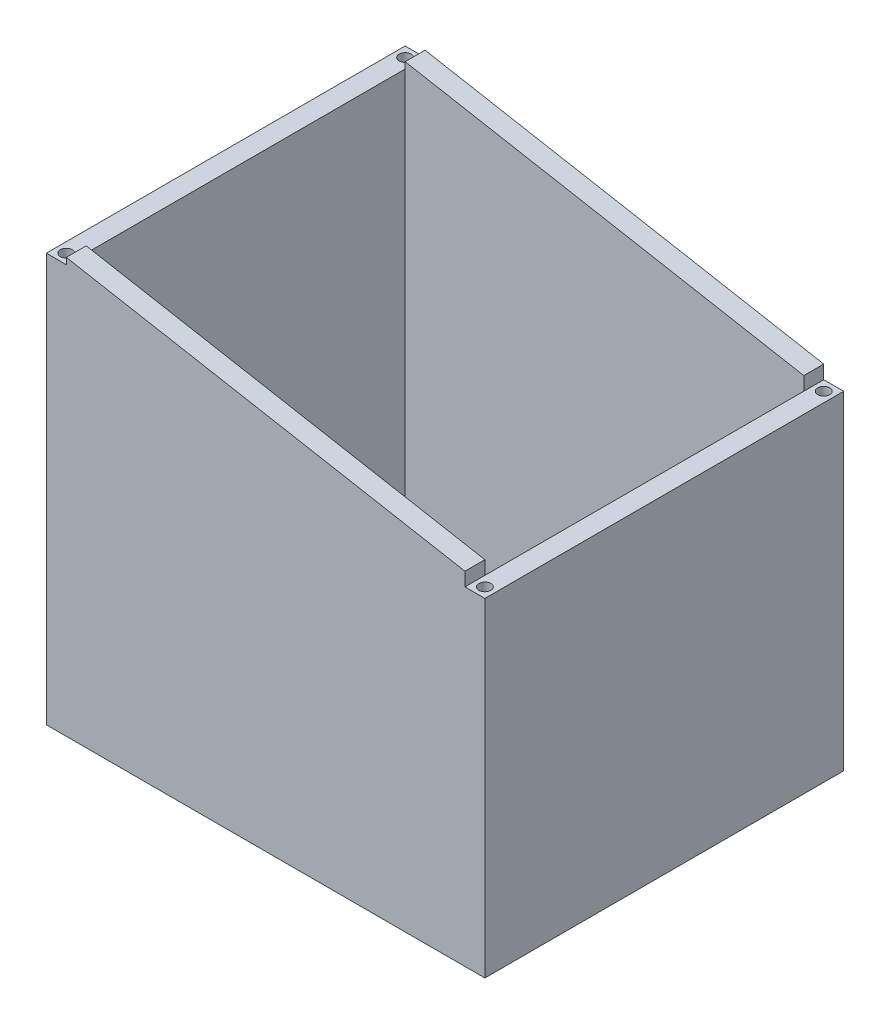
from build123d import *

# Parameters (mm, degrees)
BOSS_EXTRUDE3_DEPTH      = 80
BOSS_EXTRUDE3_DEPTH_BACK = 24.960779397
SKETCH1_W                = 110
SKETCH1_H                = 90
SKETCH1_W_2              = 100
SKETCH1_H_2              = 80
SKETCH2_R                = 1.5
CUT_EXTRUDE1_DEPTH       = 80
SKETCH3_R                = 1.5
CUT_EXTRUDE2_DEPTH       = 80
SKETCH4_R                = 1.5
CUT_EXTRUDE3_DEPTH       = 80
SKETCH5_R                = 1.5
CUT_EXTRUDE4_DEPTH       = 80
CUT_EXTRUDE5_DEPTH       = 90
SKETCH7_W                = 90
SKETCH7_H                = 2.5
CUT_EXTRUDE7_DEPTH       = 5
CUT_EXTRUDE8_DEPTH       = 90
CUT_EXTRUDE11_DEPTH      = 90
SKETCH4_3_R              = 1.5
CUT_EXTRUDE17_DEPTH      = 105
SKETCH5_3_R              = 1.5
CUT_EXTRUDE18_DEPTH      = 105
SKETCH3_3_R              = 1.5
CUT_EXTRUDE19_DEPTH      = 105
SKETCH2_3_R              = 1.5
CUT_EXTRUDE20_DEPTH      = 105
SKETCH20_W               = 58
SKETCH20_H               = 13
CUT_EXTRUDE21_DEPTH      = 5


with BuildPart() as part:
    # Sketch1 → Boss-Extrude3 (new, two sides: drawn at the far end of the back side and taken through both)
    with BuildSketch(Plane(origin=(0, 0, 0), x_dir=(1, 0, 0), z_dir=(0, 1, 0)).offset(-BOSS_EXTRUDE3_DEPTH_BACK)):
        Rectangle(SKETCH1_W, SKETCH1_H)
        Rectangle(SKETCH1_W_2, SKETCH1_H_2, mode=Mode.SUBTRACT)
    extrude(amount=BOSS_EXTRUDE3_DEPTH + BOSS_EXTRUDE3_DEPTH_BACK)

    # Sketch2 → Cut-Extrude1 (cut)
    with BuildSketch(Plane(origin=(0, 80, 0), x_dir=(1, 0, 0), z_dir=(0, 1, 0))):
        with Locations((-52.5, 42.5)):
            Circle(SKETCH2_R)
    extrude(amount=-CUT_EXTRUDE1_DEPTH, mode=Mode.SUBTRACT)

    # Sketch3 → Cut-Extrude2 (cut)
    with BuildSketch(Plane(origin=(0, 80, 0), x_dir=(1, 0, 0), z_dir=(0, 1, 0))):
        with Locations((52.5, 42.5)):
            Circle(SKETCH3_R)
    extrude(amount=-CUT_EXTRUDE2_DEPTH, mode=Mode.SUBTRACT)

    # Sketch4 → Cut-Extrude3 (cut)
    with BuildSketch(Plane(origin=(0, 80, 0), x_dir=(1, 0, 0), z_dir=(0, 1, 0))):
        with Locations((-52.5, -42.5)):
            Circle(SKETCH4_R)
    extrude(amount=-CUT_EXTRUDE3_DEPTH, mode=Mode.SUBTRACT)

    # Sketch5 → Cut-Extrude4 (cut)
    with BuildSketch(Plane(origin=(0, 80, 0), x_dir=(1, 0, 0), z_dir=(0, 1, 0))):
        with Locations((52.5, -42.5)):
            Circle(SKETCH5_R)
    extrude(amount=-CUT_EXTRUDE4_DEPTH, mode=Mode.SUBTRACT)

    # Sketch6 → Cut-Extrude5 (cut)
    with BuildSketch(Plane.XY.offset(45)):
        Polygon((-55, 80), (55, 80), (55, 60), align=None)
    extrude(amount=-CUT_EXTRUDE5_DEPTH, mode=Mode.SUBTRACT)

    # Sketch7 → Cut-Extrude7 (cut)
    with BuildSketch(Plane(origin=(55, 0, 0), x_dir=(0, 0, -1), z_dir=(1, 0, 0))):
        with Locations((0, 58.75)):
            Rectangle(SKETCH7_W, SKETCH7_H)
    extrude(amount=-CUT_EXTRUDE7_DEPTH, mode=Mode.SUBTRACT)

    # Sketch8 → Cut-Extrude8 (cut)
    with BuildSketch(Plane.XY.offset(45)):
        Polygon((50, 60), (55, 60), (50, 60.909090909), align=None)
    extrude(amount=-CUT_EXTRUDE8_DEPTH, mode=Mode.SUBTRACT)

    # Sketch9 → Cut-Extrude11 (cut)
    with BuildSketch(Plane.XY.offset(45)):
        Polygon((-55, 80), (-55, 77.5), (-50, 77.5), (-50, 79.090909091), align=None)
    extrude(amount=-CUT_EXTRUDE11_DEPTH, mode=Mode.SUBTRACT)

    # Sketch4_3 → Cut-Extrude17 (cut)
    with BuildSketch(Plane(origin=(0, 80, 0), x_dir=(1, 0, 0), z_dir=(0, 1, 0))):
        with Locations((-52.5, -42.5)):
            Circle(SKETCH4_3_R)
    extrude(amount=-CUT_EXTRUDE17_DEPTH, mode=Mode.SUBTRACT)

    # Sketch5_3 → Cut-Extrude18 (cut)
    with BuildSketch(Plane(origin=(0, 80, 0), x_dir=(1, 0, 0), z_dir=(0, 1, 0))):
        with Locations((52.5, -42.5)):
            Circle(SKETCH5_3_R)
    extrude(amount=-CUT_EXTRUDE18_DEPTH, mode=Mode.SUBTRACT)

    # Sketch3_3 → Cut-Extrude19 (cut)
    with BuildSketch(Plane(origin=(0, 80, 0), x_dir=(1, 0, 0), z_dir=(0, 1, 0))):
        with Locations((52.5, 42.5)):
            Circle(SKETCH3_3_R)
    extrude(amount=-CUT_EXTRUDE19_DEPTH, mode=Mode.SUBTRACT)

    # Sketch2_3 → Cut-Extrude20 (cut)
    with BuildSketch(Plane(origin=(0, 80, 0), x_dir=(1, 0, 0), z_dir=(0, 1, 0))):
        with Locations((-52.5, 42.5)):
            Circle(SKETCH2_3_R)
    extrude(amount=-CUT_EXTRUDE20_DEPTH, mode=Mode.SUBTRACT)

    # Sketch20 → Cut-Extrude21 (cut)
    with BuildSketch(Plane.ZY.offset(55)):
        with Locations((0, -18.460779397)):
            Rectangle(SKETCH20_W, SKETCH20_H)
    extrude(amount=-CUT_EXTRUDE21_DEPTH, mode=Mode.SUBTRACT)


solid = part.part
